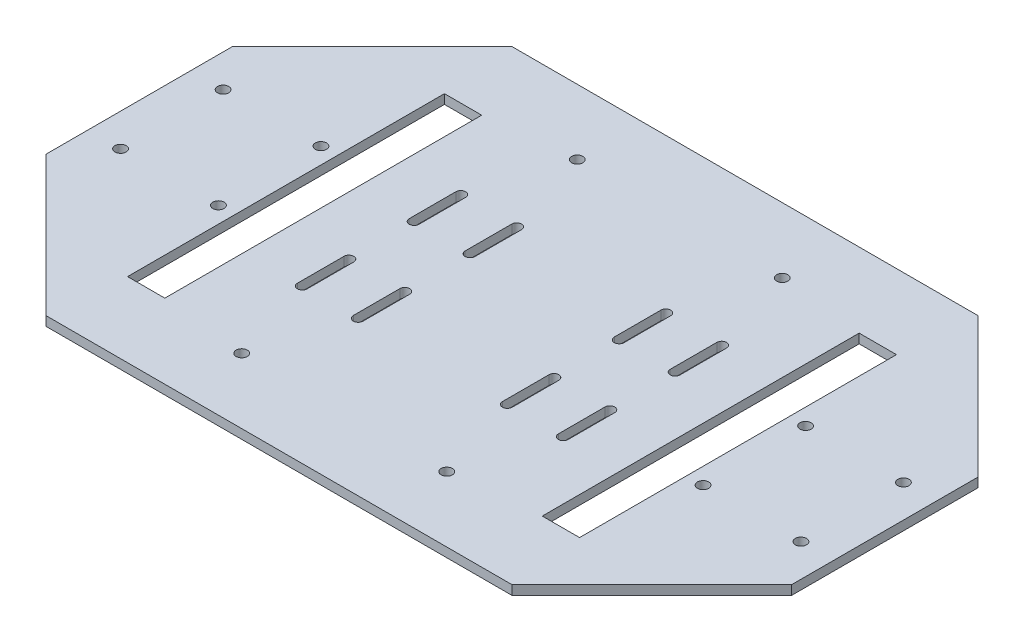
from build123d import *

# Parameters (mm, degrees)
ESQUISSE1_W                         = 160
ESQUISSE1_H                         = 100
BOSS_EXTRU_1_DEPTH                  = 2
ENL_V_MAT_EXTRU_1_DEPTH             = 2
ENL_V_MAT_EXTRU_2_DEPTH             = 2
D_GAGEMENT_M21_D                    = 2.4
D_GAGEMENT_M21_DEPTH                = 2.001
D_GAGEMENT_M22_D                    = 2.4
D_GAGEMENT_M22_DEPTH                = 2.001
ENL_V_MAT_EXTRU_5_REACH             = 4
ESQUISSE11_W                        = 8
ESQUISSE11_H                        = 68
ENL_V_MAT_EXTRU_5_DIRECTION_2_DEPTH = 1


with BuildPart() as part:
    # Esquisse1 → Boss.-Extru.1 (new body)
    with BuildSketch(Plane(origin=(0, 0, 0), x_dir=(1, 0, 0), z_dir=(0, 1, 0))):
        with Locations((80, 50)):
            Rectangle(ESQUISSE1_W, ESQUISSE1_H)
    extrude(amount=BOSS_EXTRU_1_DEPTH)

    # Esquisse2 → Enlèv. mat.-Extru.1 (cut)
    with BuildSketch(Plane(origin=(0, 2, 0), x_dir=(1, 0, 0), z_dir=(0, 1, 0))):
        Polygon((30, 0), (0, 30), (0, 0), align=None)
        Polygon((30, 100), (0, 70), (0, 100), align=None)
        Polygon((130, 0), (160, 30), (160, 0), align=None)
        Polygon((130, 100), (160, 100), (160, 70), align=None)
    extrude(amount=-ENL_V_MAT_EXTRU_1_DEPTH, mode=Mode.SUBTRACT)

    # Esquisse3 → Enlèv. mat.-Extru.2 (cut)
    with BuildSketch(Plane(origin=(0, 2, 0), x_dir=(1, 0, 0), z_dir=(0, 1, 0))):
        with BuildLine():
            Line((65.05, 43), (65.05, 33))
            ThreePointArc((65.05, 33), (64, 31.95), (62.95, 33))
            Line((62.95, 33), (62.95, 43))
            ThreePointArc((62.95, 43), (64, 44.05), (65.05, 43))
        make_face()
        with BuildLine():
            Line((50.95, 33), (50.95, 43))
            ThreePointArc((50.95, 43), (52, 44.05), (53.05, 43))
            Line((53.05, 43), (53.05, 33))
            ThreePointArc((53.05, 33), (52, 31.95), (50.95, 33))
        make_face()
        with BuildLine():
            Line((109.05, 33), (109.05, 43))
            ThreePointArc((109.05, 43), (108, 44.05), (106.95, 43))
            Line((106.95, 43), (106.95, 33))
            ThreePointArc((106.95, 33), (108, 31.95), (109.05, 33))
        make_face()
        with BuildLine():
            Line((94.95, 43), (94.95, 33))
            ThreePointArc((94.95, 33), (96, 31.95), (97.05, 33))
            Line((97.05, 33), (97.05, 43))
            ThreePointArc((97.05, 43), (96, 44.05), (94.95, 43))
        make_face()
        with BuildLine():
            Line((50.95, 67), (50.95, 57))
            ThreePointArc((50.95, 57), (52, 55.95), (53.05, 57))
            Line((53.05, 57), (53.05, 67))
            ThreePointArc((53.05, 67), (52, 68.05), (50.95, 67))
        make_face()
        with BuildLine():
            Line((65.05, 57), (65.05, 67))
            ThreePointArc((65.05, 67), (64, 68.05), (62.95, 67))
            Line((62.95, 67), (62.95, 57))
            ThreePointArc((62.95, 57), (64, 55.95), (65.05, 57))
        make_face()
        with BuildLine():
            Line((94.95, 57), (94.95, 67))
            ThreePointArc((94.95, 67), (96, 68.05), (97.05, 67))
            Line((97.05, 67), (97.05, 57))
            ThreePointArc((97.05, 57), (96, 55.95), (94.95, 57))
        make_face()
        with BuildLine():
            Line((109.05, 67), (109.05, 57))
            ThreePointArc((109.05, 57), (108, 55.95), (106.95, 57))
            Line((106.95, 57), (106.95, 67))
            ThreePointArc((106.95, 67), (108, 68.05), (109.05, 67))
        make_face()
    extrude(amount=-ENL_V_MAT_EXTRU_2_DEPTH, mode=Mode.SUBTRACT)

    # Dégagement M21
    with Locations(Plane(origin=(0, 2, 0), x_dir=(1, 0, 0), z_dir=(0, 1, 0))):
        with Locations((28, 39), (28, 61), (7, 61), (7, 39)):
            d_gagement_m21 = Hole(D_GAGEMENT_M21_D / 2, depth=D_GAGEMENT_M21_DEPTH)

    # Dégagement M22
    with Locations(Plane(origin=(0, 2, 0), x_dir=(1, 0, 0), z_dir=(0, 1, 0))):
        with Locations((58, 14), (58, 86)):
            d_gagement_m22 = Hole(D_GAGEMENT_M22_D / 2, depth=D_GAGEMENT_M22_DEPTH)

    # Symétrie1: Dégagement M21, Dégagement M22 across plane
    add(d_gagement_m21.mirror(Plane.ZY.offset(-80)), mode=Mode.SUBTRACT)
    add(d_gagement_m22.mirror(Plane.ZY.offset(-80)), mode=Mode.SUBTRACT)

    # Esquisse11 → Enlèv. mat.-Extru.5 (cut, up to next)
    with BuildSketch(Plane(origin=(0, 2, 0), x_dir=(1, 0, 0), z_dir=(0, 1, 0)), mode=Mode.PRIVATE) as enl_v_mat_extru_5_sk1:
        with Locations((35.5, 50)):
            Rectangle(ESQUISSE11_W, ESQUISSE11_H)
    enl_v_mat_extru_5_tool1 = extrude(enl_v_mat_extru_5_sk1.sketch, amount=-ENL_V_MAT_EXTRU_5_REACH, mode=Mode.PRIVATE) & part.part
    add(enl_v_mat_extru_5_tool1.solids().sort_by_distance((35.5, 2, -50))[0], mode=Mode.SUBTRACT)
    # Esquisse11 → Enlèv. mat.-Extru.5 (cut, up to next)
    with BuildSketch(Plane(origin=(0, 2, 0), x_dir=(1, 0, 0), z_dir=(0, 1, 0)), mode=Mode.PRIVATE) as enl_v_mat_extru_5_sk2:
        with Locations((124.5, 50)):
            Rectangle(ESQUISSE11_W, ESQUISSE11_H)
    enl_v_mat_extru_5_tool2 = extrude(enl_v_mat_extru_5_sk2.sketch, amount=-ENL_V_MAT_EXTRU_5_REACH, mode=Mode.PRIVATE) & part.part
    add(enl_v_mat_extru_5_tool2.solids().sort_by_distance((124.5, 2, -50))[0], mode=Mode.SUBTRACT)

    # Esquisse11 → Enlèv. mat.-Extru.5 direction 2 (cut)
    with BuildSketch(Plane(origin=(0, 2, 0), x_dir=(1, 0, 0), z_dir=(0, 1, 0))):
        with Locations((35.5, 50)):
            Rectangle(ESQUISSE11_W, ESQUISSE11_H)
        with Locations((124.5, 50)):
            Rectangle(ESQUISSE11_W, ESQUISSE11_H)
    extrude(amount=ENL_V_MAT_EXTRU_5_DIRECTION_2_DEPTH, mode=Mode.SUBTRACT)


solid = part.part
